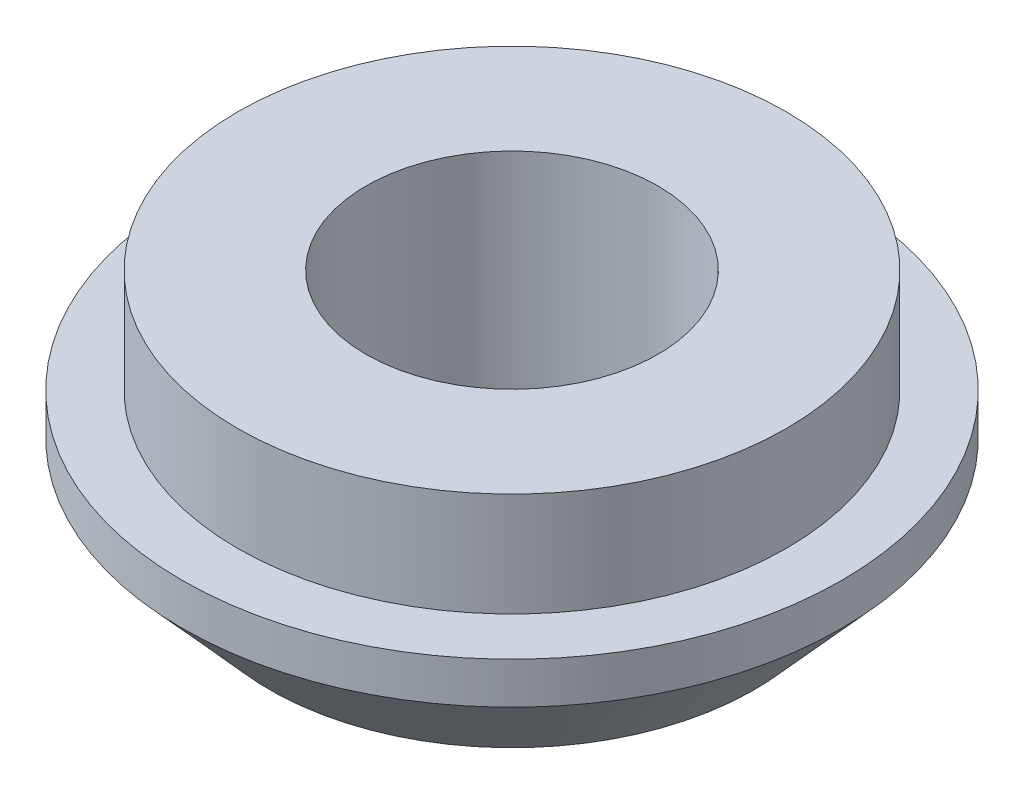
from build123d import *

# Parameters (mm, degrees)
SKETCH1_R               = 9.525
EXTRUDE1_DEPTH          = 7
SKETCH2_R               = 4
EXTRUDE2_DEPTH          = 16.18062087
F_3_8_24_TAPPED_HOLE2_D = 8.4328
SKETCH3_OUTSIDE_W       = 26.618
SKETCH3_OUTSIDE_H       = 26.618
SKETCH3_OUTSIDE_R       = 7.925
EXTRUDE3_DEPTH          = 3


with BuildPart() as part:
    # Sketch1 → Extrude1 (new body)
    with BuildSketch(Plane(origin=(0, 0, 0), x_dir=(1, 0, 0), z_dir=(0, 1, 0))):
        with Locations(Location((0, 0, 0), (0, 0, 270))):
            Circle(SKETCH1_R)
    extrude(amount=EXTRUDE1_DEPTH)

    # Sketch2 → Extrude2 (cut, through all)
    with BuildSketch(Plane(origin=(0, 0, 0), x_dir=(1, 0, 0), z_dir=(0, 1, 0))):
        Circle(SKETCH2_R)
    extrude(amount=EXTRUDE2_DEPTH, mode=Mode.SUBTRACT)

    # 3_8-24 Tapped Hole2 (through all)
    with Locations(Plane(origin=(0, 0, 0), x_dir=(-1, 0, 0), z_dir=(0, -1, 0))):
        with Locations((0, 0)):
            Hole(F_3_8_24_TAPPED_HOLE2_D / 2)

    # Sketch3 outside → Extrude3 (cut)
    with BuildSketch(Plane(origin=(0, 7, 0), x_dir=(1, 0, 0), z_dir=(0, 1, 0))):
        Rectangle(SKETCH3_OUTSIDE_W, SKETCH3_OUTSIDE_H)
        with Locations(Location((0, 0, 0), (0, 0, 270))):
            Circle(SKETCH3_OUTSIDE_R, mode=Mode.SUBTRACT)
    extrude(amount=-EXTRUDE3_DEPTH, mode=Mode.SUBTRACT)

    # Sketch6 → Cut-Revolve1 (revolve, cut)
    with BuildSketch(Plane.XY, mode=Mode.PRIVATE) as cut_revolve1_sk:
        Polygon((-9.525, 2.8), (-7, 0), (-7, -3.811390031), (-11.858524977, -3.811390031), (-11.858524977, 2.8), align=None)
    revolve(cut_revolve1_sk.sketch.rotate(Axis((0, 0, 0), (0, 1, 0)), 270), axis=Axis((0, 0, 0), (0, 1, 0)), mode=Mode.SUBTRACT)


solid = part.part
